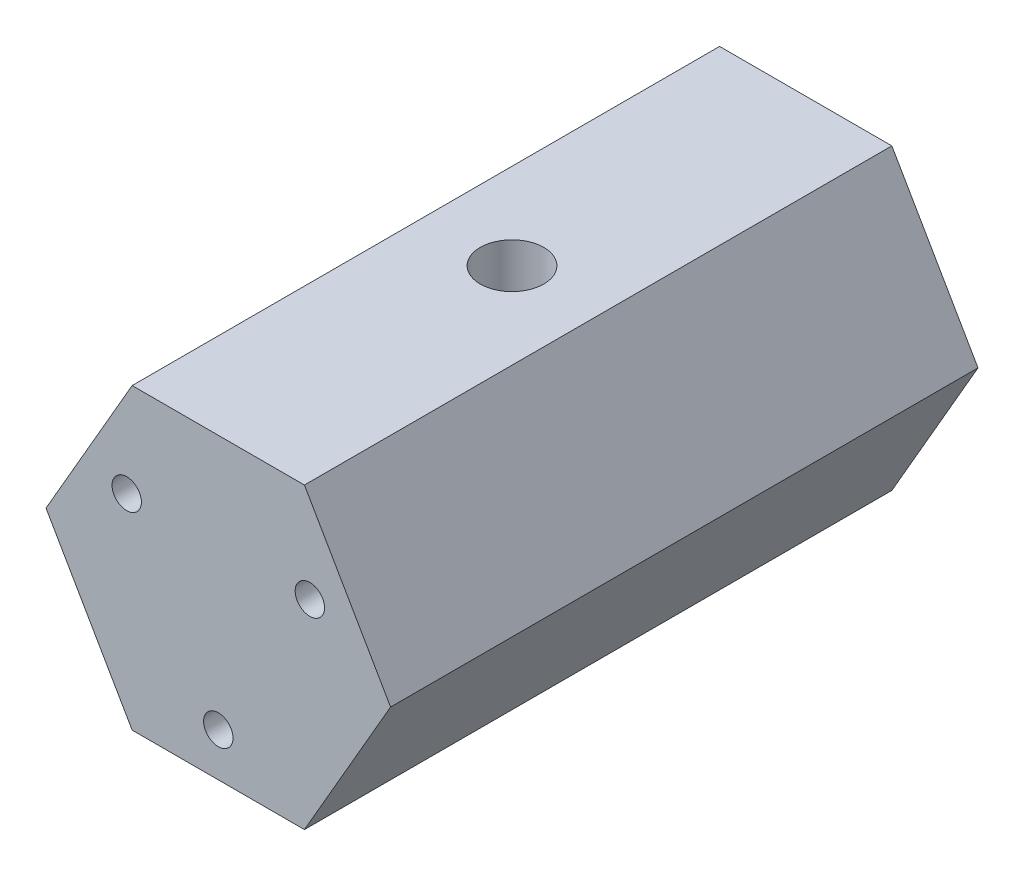
from build123d import *

# Parameters (mm, degrees)
SKETCH1_R               = 1.25
BOSS_EXTRUDE1_DEPTH     = 50
F_1_4_28_TAPPED_HOLE1_D = 5.4102


with BuildPart() as part:
    # Sketch1 → Boss-Extrude1 (new body)
    with BuildSketch(Plane.XY):
        Polygon((-7.332348419, -12.7), (7.332348419, -12.7), (14.664696837, 0), (7.332348419, 12.7), (-7.332348419, 12.7), (-14.664696837, 0), align=None)
        with Locations((-7.794228634, 4.5)):
            Circle(SKETCH1_R, mode=Mode.SUBTRACT)
        with Locations((7.794228634, 4.5)):
            Circle(SKETCH1_R, mode=Mode.SUBTRACT)
        with Locations((0, -9)):
            Circle(SKETCH1_R, mode=Mode.SUBTRACT)
    extrude(amount=BOSS_EXTRUDE1_DEPTH)

    # 1/4-28 Tapped Hole1 (through all)
    with Locations(Plane(origin=(0, 12.7, 0), x_dir=(1, 0, 0), z_dir=(0, 1, 0))):
        with Locations((0, -25)):
            Hole(F_1_4_28_TAPPED_HOLE1_D / 2)


solid = part.part
